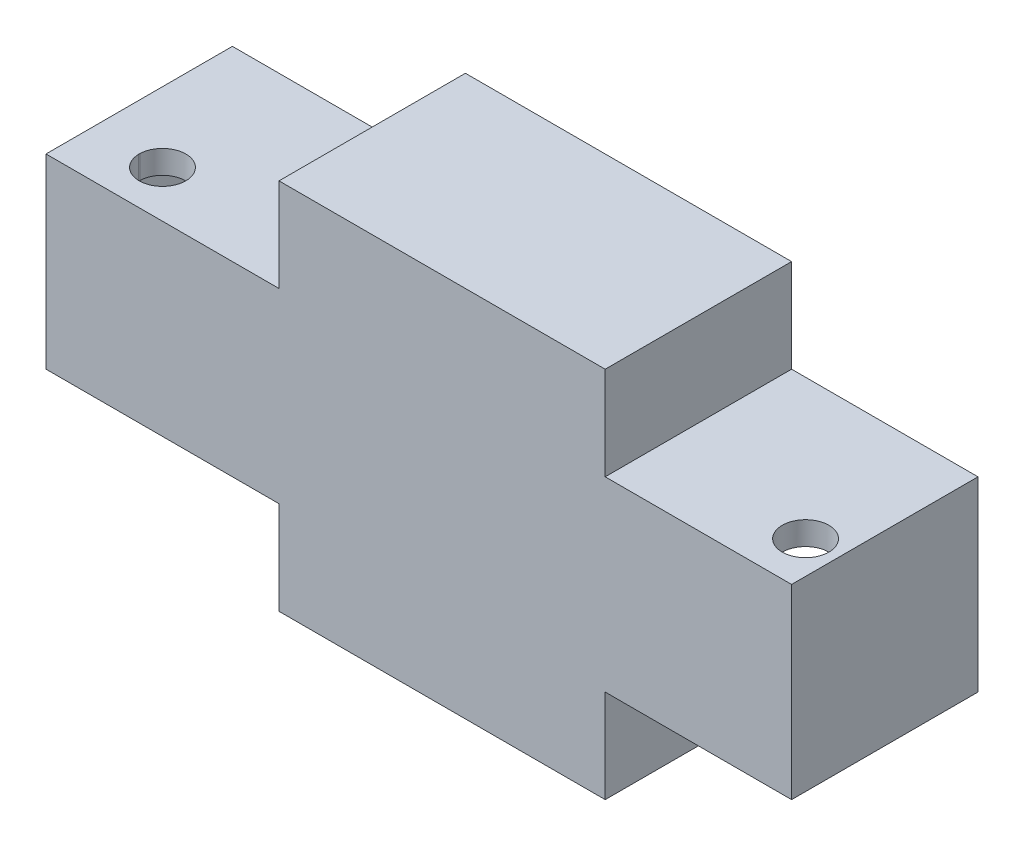
from build123d import *

# Parameters (mm, degrees)
SKETCH2_W               = 6.35
SKETCH2_H               = 50.8
SKETCH2_W_2             = 2.54
SKETCH2_W_3             = 31.75
SKETCH2_W_4             = 3.81
SKETCH2_W_5             = 12.7
BOSS_EXTRUDE2_DEPTH     = 73.66
CUT_EXTRUDE2_DEPTH      = 26.4
CUT_EXTRUDE2_DEPTH_BACK = 77.2
CUT_EXTRUDE3_DEPTH      = 22.86
CUT_EXTRUDE4_DEPTH      = 38.1


with BuildPart() as part:
    # Sketch2 → Boss-Extrude2 (new body)
    with BuildSketch(Plane.XY):
        with Locations((98.925952955, 12.684680338)):
            Rectangle(SKETCH2_W, SKETCH2_H)
        with Locations((105.275952955, 12.684680338)):
            Rectangle(SKETCH2_W, SKETCH2_H)
        with Locations((109.720952955, 12.684680338)):
            Rectangle(SKETCH2_W_2, SKETCH2_H)
        with Locations((79.875952955, 12.684680338)):
            Rectangle(SKETCH2_W_3, SKETCH2_H)
        with Locations((62.095952955, 12.684680338)):
            Rectangle(SKETCH2_W_4, SKETCH2_H)
        Polygon((-28.709047045, -38.115319662), (60.190952955, -38.115319662), (60.190952955, 63.484680338), (-28.709047045, 63.484680338), (-28.709047045, -12.715319662), align=None)
        with Locations((-31.884047045, 12.684680338)):
            Rectangle(SKETCH2_W, SKETCH2_H)
        with Locations((-50.934047045, 12.684680338)):
            Rectangle(SKETCH2_W_3, SKETCH2_H)
        with Locations((-69.984047045, 12.684680338)):
            Rectangle(SKETCH2_W, SKETCH2_H)
        with Locations((-76.334047045, 12.684680338)):
            Rectangle(SKETCH2_W, SKETCH2_H)
        with Locations((-85.859047045, 12.684680338)):
            Rectangle(SKETCH2_W_5, SKETCH2_H)
    extrude(amount=BOSS_EXTRUDE2_DEPTH)

    # Sketch4 → Cut-Extrude2 (cut, two sides)
    with BuildSketch(Plane(origin=(0, 38.084680338, 0), x_dir=(1, 0, 0), z_dir=(0, 1, 0))) as cut_extrude2_sk:
        with BuildLine():
            Line((-73.159047045, -60.96), (-73.159047045, -67.31))
            ThreePointArc((-73.159047045, -67.31), (-68.668918984, -65.450128061), (-66.809047045, -60.96))
            ThreePointArc((-66.809047045, -60.96), (-68.668918984, -56.469871939), (-73.159047045, -54.61))
            Line((-73.159047045, -54.61), (-73.159047045, -60.96))
        make_face()
        with BuildLine():
            Line((-79.50524406, -60.740265064), (-79.50524406, -61.179734936))
            ThreePointArc((-79.50524406, -61.179734936), (-77.57080311, -65.527155397), (-73.159047045, -67.31))
            Line((-73.159047045, -67.31), (-73.159047045, -60.96))
            Line((-73.159047045, -60.96), (-73.159047045, -54.61))
            ThreePointArc((-73.159047045, -54.61), (-77.57080311, -56.392844603), (-79.50524406, -60.740265064))
        make_face()
        with BuildLine():
            ThreePointArc((102.100952955, -54.61), (97.610824895, -56.469871939), (95.750952955, -60.96))
            ThreePointArc((95.750952955, -60.96), (97.610824895, -65.450128061), (102.100952955, -67.31))
            Line((102.100952955, -67.31), (102.100952955, -60.96))
            Line((102.100952955, -60.96), (102.100952955, -54.61))
        make_face()
        with BuildLine():
            ThreePointArc((108.450952955, -60.96), (106.591081016, -56.469871939), (102.100952955, -54.61))
            Line((102.100952955, -54.61), (102.100952955, -60.96))
            Line((102.100952955, -60.96), (102.100952955, -67.31))
            ThreePointArc((102.100952955, -67.31), (106.591081016, -65.450128061), (108.450952955, -60.96))
        make_face()
    extrude(amount=CUT_EXTRUDE2_DEPTH, mode=Mode.SUBTRACT)
    extrude(cut_extrude2_sk.sketch, amount=-CUT_EXTRUDE2_DEPTH_BACK, mode=Mode.SUBTRACT)

    # Sketch5 → Cut-Extrude3 (cut)
    with BuildSketch(Plane(origin=(0, 0, 0), x_dir=(-1, 0, 0), z_dir=(0, 0, -1))):
        Polygon((-60.190952955, -38.115319662), (-60.190952955, -12.715319662), (-110.990952955, -12.715319662), (-110.990952955, 38.084680338), (-60.190952955, 38.084680338), (-60.190952955, 63.484680338), (28.709047045, 63.484680338), (28.709047045, 38.084680338), (92.209047045, 38.084680338), (92.209047045, -12.715319662), (28.709047045, -12.715319662), (28.709047045, -38.115319662), align=None)
    extrude(amount=-CUT_EXTRUDE3_DEPTH, mode=Mode.SUBTRACT)

    # Sketch8 → Cut-Extrude4 (cut)
    with BuildSketch(Plane(origin=(0, 0, 22.86), x_dir=(-1, 0, 0), z_dir=(0, 0, -1))):
        Polygon((-104.640952955, -6.365319662), (-53.840952955, -6.365319662), (-53.840952955, -31.765319662), (22.359047045, -31.765319662), (22.359047045, -6.365319662), (85.859047045, -6.365319662), (85.859047045, 31.734680338), (22.359047045, 31.734680338), (22.359047045, 57.134680338), (-53.840952955, 57.134680338), (-53.840952955, 31.734680338), (-104.640952955, 31.734680338), align=None)
    extrude(amount=-CUT_EXTRUDE4_DEPTH, mode=Mode.SUBTRACT)


solid = part.part
